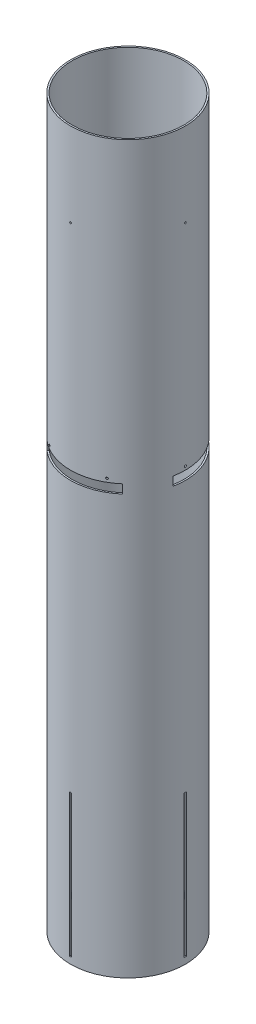
from build123d import *

# Parameters (mm, degrees)
SKETCH1_R                 = 78.359
SKETCH1_R_2               = 76.2
BOSS_EXTRUDE1_DEPTH       = 990.6
FIN_SLOTS_DEPTH           = 997.779125866
CIRPATTERN1_COUNT         = 4
CUT_EXTRUDE2_DEPTH        = 997.779125866
CIRPATTERN2_COUNT         = 6
SKETCH3_R                 = 3.175
CUT_EXTRUDE3_DEPTH        = 997.779125981
CUT_EXTRUDE4_START        = -12.065
CUT_EXTRUDE4_DEPTH        = 12.065
CIRPATTERN3_COUNT         = 3
SKETCH2_4_R               = 1.0922
SHEAR_SCREW_HOLES_DEPTH   = 997.779125981
SHEAR_SCREW_PATTERN_COUNT = 4


with BuildPart() as part:
    # Sketch1 → Boss-Extrude1 (new body)
    with BuildSketch(Plane(origin=(0, 0, 0), x_dir=(1, 0, 0), z_dir=(0, 1, 0))):
        Circle(SKETCH1_R)
        Circle(SKETCH1_R_2, mode=Mode.SUBTRACT)
    extrude(amount=BOSS_EXTRUDE1_DEPTH)

    # Sketch2 → Fin Slots (cut, through all)
    with BuildSketch(Plane(origin=(0, 0, 0), x_dir=(0, 0, -1), z_dir=(1, 0, 0))):
        Polygon((0, 8.89), (1.5875, 8.89), (1.5875, 203.2), (-1.5875, 203.2), (-1.5875, 8.89), align=None)
    fin_slots = extrude(amount=-FIN_SLOTS_DEPTH, mode=Mode.SUBTRACT)

    # CirPattern1: Fin Slots ×4 about axis
    cirpattern1_axis = Axis((0, 0, 0), (0, 1, 0))
    for i in range(1, CIRPATTERN1_COUNT):
        add(fin_slots.rotate(cirpattern1_axis, i * 360 / CIRPATTERN1_COUNT), mode=Mode.SUBTRACT)

    # Sketch2_3 → Cut-Extrude2 (cut, through all)
    with BuildSketch(Plane(origin=(0, 0, 0), x_dir=(0, 0, -1), z_dir=(1, 0, 0))):
        with BuildLine():
            ThreePointArc((1.35255, 588.645), (0.956397277, 589.601397277), (0, 589.99755))
            ThreePointArc((0, 589.99755), (-0.956397277, 587.688602723), (1.35255, 588.645))
        make_face()
    cut_extrude2 = extrude(amount=-CUT_EXTRUDE2_DEPTH, mode=Mode.SUBTRACT)

    # CirPattern2: Cut-Extrude2 ×6 about axis
    cirpattern2_axis = Axis((0, 990.6, 0), (0, -1, 0))
    for i in range(1, CIRPATTERN2_COUNT):
        add(cut_extrude2.rotate(cirpattern2_axis, i * 360 / CIRPATTERN2_COUNT), mode=Mode.SUBTRACT)

    # Sketch3 → Cut-Extrude3 (cut, through all)
    with BuildSketch(Plane(origin=(0, 0, 0), x_dir=(0.7071067811865477, 0, -0.7071067811865475), z_dir=(0.7071067811865475, 0, 0.7071067811865477))):
        with Locations((0, 127)):
            Circle(SKETCH3_R)
    extrude(amount=-CUT_EXTRUDE3_DEPTH, mode=Mode.SUBTRACT)

    # Sketch7 → Cut-Extrude4 (cut)
    with BuildSketch(Plane(origin=(0, 583.8825, 0), x_dir=(1, 0, 0), z_dir=(0, 1, 0)).offset(CUT_EXTRUDE4_START)):
        with BuildLine():
            Line((-76.853353787, -15.287082543), (-74.735838367, -14.865882538))
            ThreePointArc((-74.735838367, -14.865882538), (-65.991135768, 38.1), (-24.493687256, 72.156075868))
            Line((-24.493687256, 72.156075868), (-25.187675062, 74.200498017))
            ThreePointArc((-25.187675062, 74.200498017), (-31.722088262, 71.650833891), (-38.002320334, 68.527049624))
            ThreePointArc((-38.002320334, 68.527049624), (-39.1795, 67.860884615), (-40.345005654, 67.174499624))
            ThreePointArc((-40.345005654, 67.174499624), (-67.860884615, 39.1795), (-78.347325988, 1.35255))
            ThreePointArc((-78.347325988, 1.35255), (-78.359, 0), (-78.347325988, -1.35255))
            ThreePointArc((-78.347325988, -1.35255), (-77.912486483, -8.35328265), (-76.853353787, -15.287082543))
        make_face()
    cut_extrude4 = extrude(amount=CUT_EXTRUDE4_DEPTH, mode=Mode.SUBTRACT)

    # CirPattern3: Cut-Extrude4 ×3 about axis
    cirpattern3_axis = Axis((0, 990.6, 0), (0, -1, 0))
    for i in range(1, CIRPATTERN3_COUNT):
        add(cut_extrude4.rotate(cirpattern3_axis, i * 360 / CIRPATTERN3_COUNT), mode=Mode.SUBTRACT)

    # Sketch2_4 → Shear Screw Holes (cut, through all)
    with BuildSketch(Plane(origin=(0, 0, 0), x_dir=(0, 0, -1), z_dir=(1, 0, 0))):
        with Locations((0, 876.3)):
            Circle(SKETCH2_4_R)
    shear_screw_holes = extrude(amount=-SHEAR_SCREW_HOLES_DEPTH, mode=Mode.SUBTRACT)

    # Shear Screw Pattern: Shear Screw Holes ×4 about axis
    shear_screw_pattern_axis = Axis((0, 990.6, 0), (0, -1, 0))
    for i in range(1, SHEAR_SCREW_PATTERN_COUNT):
        add(shear_screw_holes.rotate(shear_screw_pattern_axis, i * 360 / SHEAR_SCREW_PATTERN_COUNT), mode=Mode.SUBTRACT)


solid = part.part
